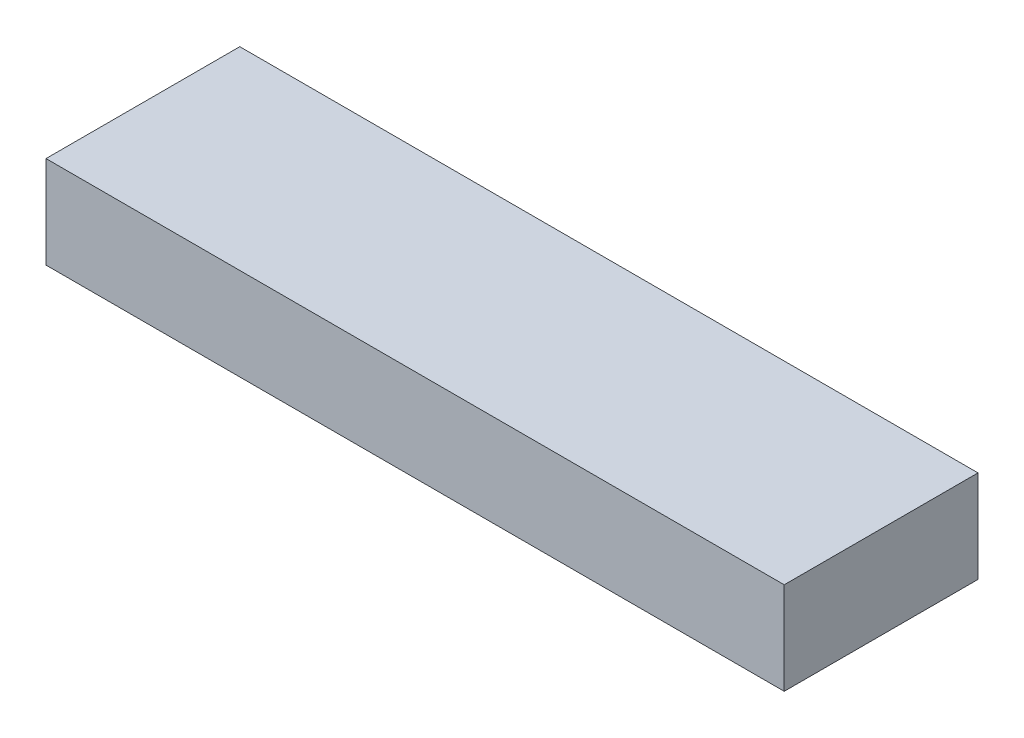
from build123d import *

# Parameters (mm, degrees)
SKETCH_1_W      = 80
SKETCH_1_H      = 21
EXTRUDE_1_DEPTH = 10


with BuildPart() as part:
    # Эскиз1 → Бобышка-Вытянуть1 (new body)
    with BuildSketch(Plane(origin=(0, 0, 0), x_dir=(1, 0, 0), z_dir=(0, 1, 0))):
        Rectangle(SKETCH_1_W, SKETCH_1_H)
    extrude(amount=EXTRUDE_1_DEPTH)


solid = part.part
